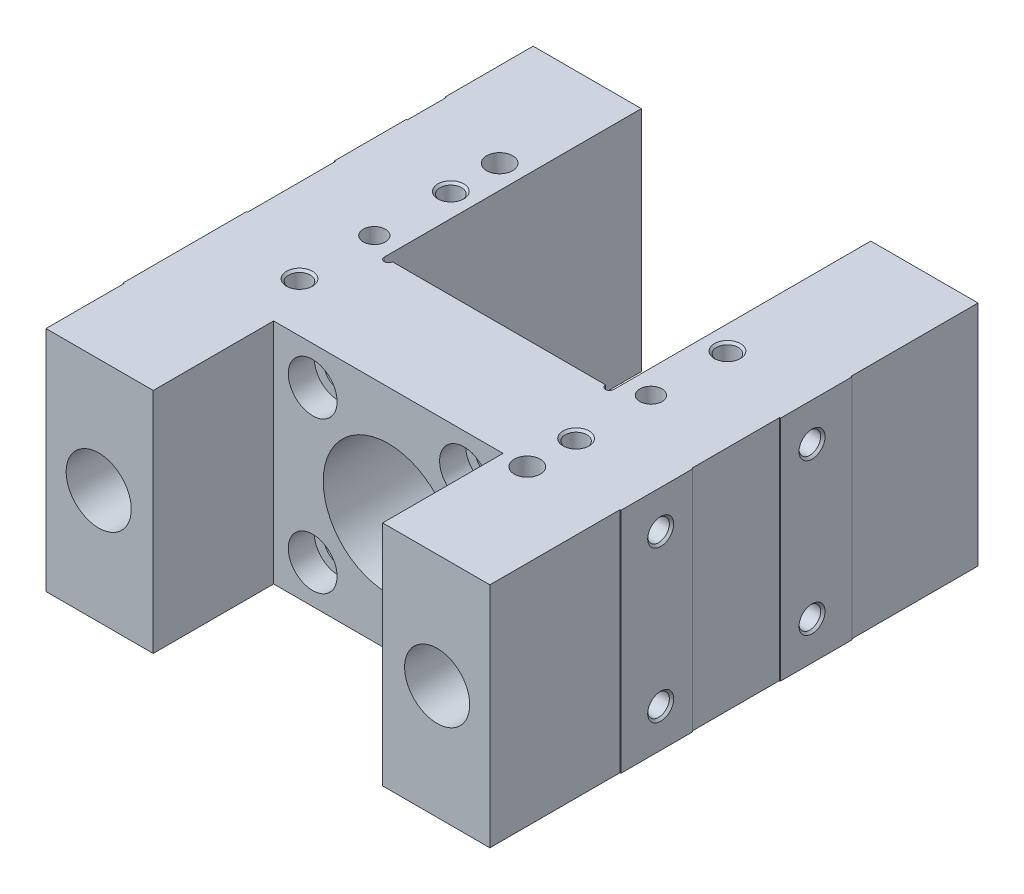
from build123d import *

# Parameters (mm, degrees)
BOSS_EXTRUDE1_DEPTH      = 35
BOSS_EXTRUDE1_DEPTH_BACK = 35
SKETCH2_W                = 36
SKETCH2_H                = 20
HOLE1_D                  = 6.647
HOLE1_DEPTH              = 19.414509714
HOLE1_CSINK_D            = 8
HOLE1_CSINK_ANGLE        = 90
HOLE1_TIP                = 1.91882362
HOLE2_D                  = 6.647
HOLE2_DEPTH              = 19.414509714
HOLE2_CSINK_D            = 8
HOLE2_CSINK_ANGLE        = 90
HOLE2_TIP                = 1.91882362
HOLE3_D                  = 6.647
HOLE3_DEPTH              = 19.414509714
HOLE3_CSINK_D            = 8
HOLE3_CSINK_ANGLE        = 90
HOLE3_TIP                = 1.91882362
SKETCH26_R               = 10
CUT_EXTRUDE1_DEPTH       = 150
SKETCH27_R               = 10
CUT_EXTRUDE2_DEPTH       = 150
CUT_EXTRUDE3_DEPTH       = 70
CUT_EXTRUDE3_DEPTH_BACK  = 70
SKETCH28_W               = 177
SKETCH28_H               = 190
SKETCH29_R               = 4
CUT_EXTRUDE4_DEPTH       = 17.5
M8_TAPPED_HOLE1_D        = 6.8
M8_TAPPED_HOLE1_DEPTH    = 19.75
M8_TAPPED_HOLE1_TIP      = 2.042926105


with BuildPart() as part:
    # Sketch1 → Boss-Extrude1 (new, two sides: drawn at the far end of the back side and taken through both)
    with BuildSketch(Plane(origin=(0, 0, 0), x_dir=(1, 0, 0), z_dir=(0, 1, 0)).offset(-BOSS_EXTRUDE1_DEPTH_BACK)):
        with BuildLine():
            Line((-68.5, -71), (-35.25, -71))
            Line((-35.25, -71), (-35.25, -34))
            Line((-35.25, -34), (35.25, -34))
            Line((35.25, -34), (35.25, -71))
            Line((35.25, -71), (68.5, -71))
            Line((68.5, -71), (68.5, 79))
            Line((68.5, 79), (35.25, 79))
            Line((35.25, 79), (35.25, 0))
            ThreePointArc((35.25, 0), (34, -1.25), (32.75, 0))
            Line((32.75, 0), (-32.75, 0))
            ThreePointArc((-32.75, 0), (-34, -1.25), (-35.25, 0))
            Line((-35.25, 0), (-35.25, 79))
            Line((-35.25, 79), (-68.5, 79))
            Line((-68.5, 79), (-68.5, -71))
        make_face()
    extrude(amount=BOSS_EXTRUDE1_DEPTH + BOSS_EXTRUDE1_DEPTH_BACK)

    # Sketch2 → Cut-Revolve1 (revolve, cut)
    with BuildSketch(Plane(origin=(0, 0, 0), x_dir=(0, 0, -1), z_dir=(1, 0, 0))):
        with Locations((-17, 10)):
            Rectangle(SKETCH2_W, SKETCH2_H)
    revolve(axis=Axis((0, 0, -1), (0, 0, 1)), mode=Mode.SUBTRACT)

    # Sketch3 → Cut-Revolve2 (revolve, cut)
    with BuildSketch(Plane(origin=(-23.25, 0, 0), x_dir=(0, 0, -1), z_dir=(1, 0, 0))):
        Polygon((-34, 23.25), (-34, 30.75), (-26, 30.75), (-26, 27.75), (0, 27.75), (0, 23.25), align=None)
    revolve(axis=Axis((-23.25, 23.25, 0), (0, 0, 1)), mode=Mode.SUBTRACT)

    # Sketch4 → Cut-Revolve3 (revolve, cut)
    with BuildSketch(Plane(origin=(-23.25, 0, 0), x_dir=(0, 0, -1), z_dir=(1, 0, 0))):
        Polygon((-34, -23.25), (-34, -15.75), (-26, -15.75), (-26, -18.75), (0, -18.75), (0, -23.25), align=None)
    revolve(axis=Axis((-23.25, -23.25, 0), (0, 0, 1)), mode=Mode.SUBTRACT)

    # Sketch5 → Cut-Revolve4 (revolve, cut)
    with BuildSketch(Plane(origin=(23.25, 0, 0), x_dir=(0, 0, -1), z_dir=(1, 0, 0))):
        Polygon((-34, 23.25), (-34, 30.75), (-26, 30.75), (-26, 27.75), (0, 27.75), (0, 23.25), align=None)
    revolve(axis=Axis((23.25, 23.25, 0), (0, 0, 1)), mode=Mode.SUBTRACT)

    # Sketch6 → Cut-Revolve5 (revolve, cut)
    with BuildSketch(Plane(origin=(23.25, 0, 0), x_dir=(0, 0, -1), z_dir=(1, 0, 0))):
        Polygon((-34, -23.25), (-34, -15.75), (-26, -15.75), (-26, -18.75), (0, -18.75), (0, -23.25), align=None)
    revolve(axis=Axis((23.25, -23.25, 0), (0, 0, 1)), mode=Mode.SUBTRACT)

    # Hole1
    with Locations(Plane(origin=(0, 35, 0), x_dir=(1, 0, 0), z_dir=(0, 1, 0))):
        with Locations((42.5, -18.8)):
            CounterSinkHole(HOLE1_D / 2, HOLE1_CSINK_D / 2, depth=HOLE1_DEPTH, counter_sink_angle=HOLE1_CSINK_ANGLE)
            with Locations((0, 0, -(HOLE1_DEPTH + HOLE1_TIP / 2))):  # 120° drill point
                Cone(0, HOLE1_D / 2, HOLE1_TIP, mode=Mode.SUBTRACT)

    # Hole2
    with Locations(Plane(origin=(0, 35, 0), x_dir=(1, 0, 0), z_dir=(0, 1, 0))):
        with Locations((-42.5, -18.8)):
            CounterSinkHole(HOLE2_D / 2, HOLE2_CSINK_D / 2, depth=HOLE2_DEPTH, counter_sink_angle=HOLE2_CSINK_ANGLE)
            with Locations((0, 0, -(HOLE2_DEPTH + HOLE2_TIP / 2))):  # 120° drill point
                Cone(0, HOLE2_D / 2, HOLE2_TIP, mode=Mode.SUBTRACT)

    # Sketch11 → Cut-Revolve6 (revolve, cut)
    with BuildSketch(Plane.XY.offset(18.8)):
        Polygon((48.5, 23.25), (50.41882362, 26.5735), (67.8235, 26.5735), (68.5, 27.25), (68.5, 23.25), align=None)
    revolve(axis=Axis((68.5, 23.25, 18.8), (-1, 0, 0)), mode=Mode.SUBTRACT)

    # Sketch12 → Cut-Revolve7 (revolve, cut)
    with BuildSketch(Plane.XY.offset(18.8)):
        Polygon((48.5, -23.25), (50.41882362, -19.9265), (67.8235, -19.9265), (68.5, -19.25), (68.5, -23.25), align=None)
    revolve(axis=Axis((68.5, -23.25, 18.8), (-1, 0, 0)), mode=Mode.SUBTRACT)

    # Sketch13 → Cut-Revolve8 (revolve, cut)
    with BuildSketch(Plane.XY.offset(18.8)):
        Polygon((-68.5, 23.25), (-68.5, 27.25), (-67.8235, 26.5735), (-50.41882362, 26.5735), (-48.5, 23.25), align=None)
    revolve(axis=Axis((-48.5, 23.25, 18.8), (-1, 0, 0)), mode=Mode.SUBTRACT)

    # Sketch14 → Cut-Revolve9 (revolve, cut)
    with BuildSketch(Plane.XY.offset(18.8)):
        Polygon((-68.5, -23.25), (-68.5, -19.25), (-67.8235, -19.9265), (-50.41882362, -19.9265), (-48.5, -23.25), align=None)
    revolve(axis=Axis((-48.5, -23.25, 18.8), (-1, 0, 0)), mode=Mode.SUBTRACT)

    # Hole3
    with Locations(Plane(origin=(0, 35, 0), x_dir=(1, 0, 0), z_dir=(0, 1, 0))):
        with Locations((42.5, 27.7)):
            CounterSinkHole(HOLE3_D / 2, HOLE3_CSINK_D / 2, depth=HOLE3_DEPTH, counter_sink_angle=HOLE3_CSINK_ANGLE)
            with Locations((0, 0, -(HOLE3_DEPTH + HOLE3_TIP / 2))):  # 120° drill point
                Cone(0, HOLE3_D / 2, HOLE3_TIP, mode=Mode.SUBTRACT)

    # Sketch17 → Cut-Revolve10 (revolve, cut)
    with BuildSketch(Plane.XY.offset(-27.7)):
        Polygon((-42.5, 35), (-38.5, 35), (-39.1765, 34.3235), (-39.1765, 15.585490286), (-42.5, 13.666666667), align=None)
    revolve(axis=Axis((-42.5, 13.666666667, -27.7), (0, 1, 0)), mode=Mode.SUBTRACT)

    # Sketch18 → Cut-Revolve11 (revolve, cut)
    with BuildSketch(Plane.XY.offset(-27.7)):
        Polygon((48.5, 23.25), (50.41882362, 26.5735), (67.8235, 26.5735), (68.5, 27.25), (68.5, 23.25), align=None)
    revolve(axis=Axis((68.5, 23.25, -27.7), (-1, 0, 0)), mode=Mode.SUBTRACT)

    # Sketch19 → Cut-Revolve12 (revolve, cut)
    with BuildSketch(Plane.XY.offset(-27.7)):
        Polygon((48.5, -23.25), (50.41882362, -19.9265), (67.8235, -19.9265), (68.5, -19.25), (68.5, -23.25), align=None)
    revolve(axis=Axis((68.5, -23.25, -27.7), (-1, 0, 0)), mode=Mode.SUBTRACT)

    # Sketch20 → Cut-Revolve13 (revolve, cut)
    with BuildSketch(Plane.XY.offset(-27.7)):
        Polygon((-68.5, 23.25), (-68.5, 27.25), (-67.8235, 26.5735), (-50.41882362, 26.5735), (-48.5, 23.25), align=None)
    revolve(axis=Axis((-48.5, 23.25, -27.7), (-1, 0, 0)), mode=Mode.SUBTRACT)

    # Sketch21 → Cut-Revolve14 (revolve, cut)
    with BuildSketch(Plane.XY.offset(-27.7)):
        Polygon((-68.5, -23.25), (-68.5, -19.25), (-67.8235, -19.9265), (-50.41882362, -19.9265), (-48.5, -23.25), align=None)
    revolve(axis=Axis((-48.5, -23.25, -27.7), (-1, 0, 0)), mode=Mode.SUBTRACT)

    # Sketch22 → Cut-Revolve15 (revolve, cut)
    with BuildSketch(Plane.XY.offset(-63)):
        Polygon((-68.5, 23.25), (-68.5, 27.25), (-67.8235, 26.5735), (-50.41882362, 26.5735), (-48.5, 23.25), align=None)
    revolve(axis=Axis((-48.5, 23.25, -63), (-1, 0, 0)), mode=Mode.SUBTRACT)

    # Sketch23 → Cut-Revolve16 (revolve, cut)
    with BuildSketch(Plane.XY.offset(-63)):
        Polygon((-68.5, -23.25), (-68.5, -19.25), (-67.8235, -19.9265), (-50.41882362, -19.9265), (-48.5, -23.25), align=None)
    revolve(axis=Axis((-48.5, -23.25, -63), (-1, 0, 0)), mode=Mode.SUBTRACT)

    # Sketch24 → Cut-Revolve17 (revolve, cut)
    with BuildSketch(Plane.XY.offset(37)):
        Polygon((-68.5, 23.25), (-68.5, 27.25), (-67.8235, 26.5735), (-50.41882362, 26.5735), (-48.5, 23.25), align=None)
    revolve(axis=Axis((-48.5, 23.25, 37), (-1, 0, 0)), mode=Mode.SUBTRACT)

    # Sketch25 → Cut-Revolve18 (revolve, cut)
    with BuildSketch(Plane.XY.offset(37)):
        Polygon((-68.5, -23.25), (-68.5, -19.25), (-67.8235, -19.9265), (-50.41882362, -19.9265), (-48.5, -23.25), align=None)
    revolve(axis=Axis((-48.5, -23.25, 37), (-1, 0, 0)), mode=Mode.SUBTRACT)

    # Sketch26 → Cut-Extrude1 (cut)
    with BuildSketch(Plane.XY.offset(-79)):
        with Locations((52, 0)):
            Circle(SKETCH26_R)
    extrude(amount=CUT_EXTRUDE1_DEPTH, mode=Mode.SUBTRACT)

    # Sketch27 → Cut-Extrude2 (cut)
    with BuildSketch(Plane.XY.offset(-79)):
        with Locations((-52, 0)):
            Circle(SKETCH27_R)
    extrude(amount=CUT_EXTRUDE2_DEPTH, mode=Mode.SUBTRACT)

    # Sketch28 → Cut-Extrude3 (cut, two sides: drawn at the far end of the back side and taken through both)
    with BuildSketch(Plane(origin=(0, 0, 0), x_dir=(1, 0, 0), z_dir=(0, 1, 0)).offset(-CUT_EXTRUDE3_DEPTH_BACK)):
        with Locations((0, 4)):
            Rectangle(SKETCH28_W, SKETCH28_H)
        Polygon((-68.5, 18), (-68.2, 18), (-68.2, -9), (-68.5, -9), (-68.5, -47), (-68.2, -47), (-68.2, -71), (68.2, -71), (68.2, -31), (68.5, -31), (68.5, -9), (68.2, -9), (68.2, 18), (68.5, 18), (68.5, 40), (68.2, 40), (68.2, 79), (-68.5, 79), (-68.5, 52), (-68.2, 52), (-68.2, 40), (-68.5, 40), align=None, mode=Mode.SUBTRACT)
    extrude(amount=CUT_EXTRUDE3_DEPTH + CUT_EXTRUDE3_DEPTH_BACK, mode=Mode.SUBTRACT)

    # Sketch29 → Cut-Extrude4 (cut)
    with BuildSketch(Plane(origin=(0, 35, 0), x_dir=(1, 0, 0), z_dir=(0, 1, 0))):
        with Locations((-42.5, 42.7)):
            Circle(SKETCH29_R)
        with Locations((42.5, -33.8)):
            Circle(SKETCH29_R)
    extrude(amount=-CUT_EXTRUDE4_DEPTH, mode=Mode.SUBTRACT)

    # M8 Tapped Hole1
    with Locations(Plane(origin=(0, 35, 0), x_dir=(1, 0, 0), z_dir=(0, 1, 0))):
        with Locations((-42.5, 4.2), (42.5, 4.2)):
            Hole(M8_TAPPED_HOLE1_D / 2, depth=M8_TAPPED_HOLE1_DEPTH)
            with Locations((0, 0, -(M8_TAPPED_HOLE1_DEPTH + M8_TAPPED_HOLE1_TIP / 2))):  # 118° drill point
                Cone(0, M8_TAPPED_HOLE1_D / 2, M8_TAPPED_HOLE1_TIP, mode=Mode.SUBTRACT)


solid = part.part
